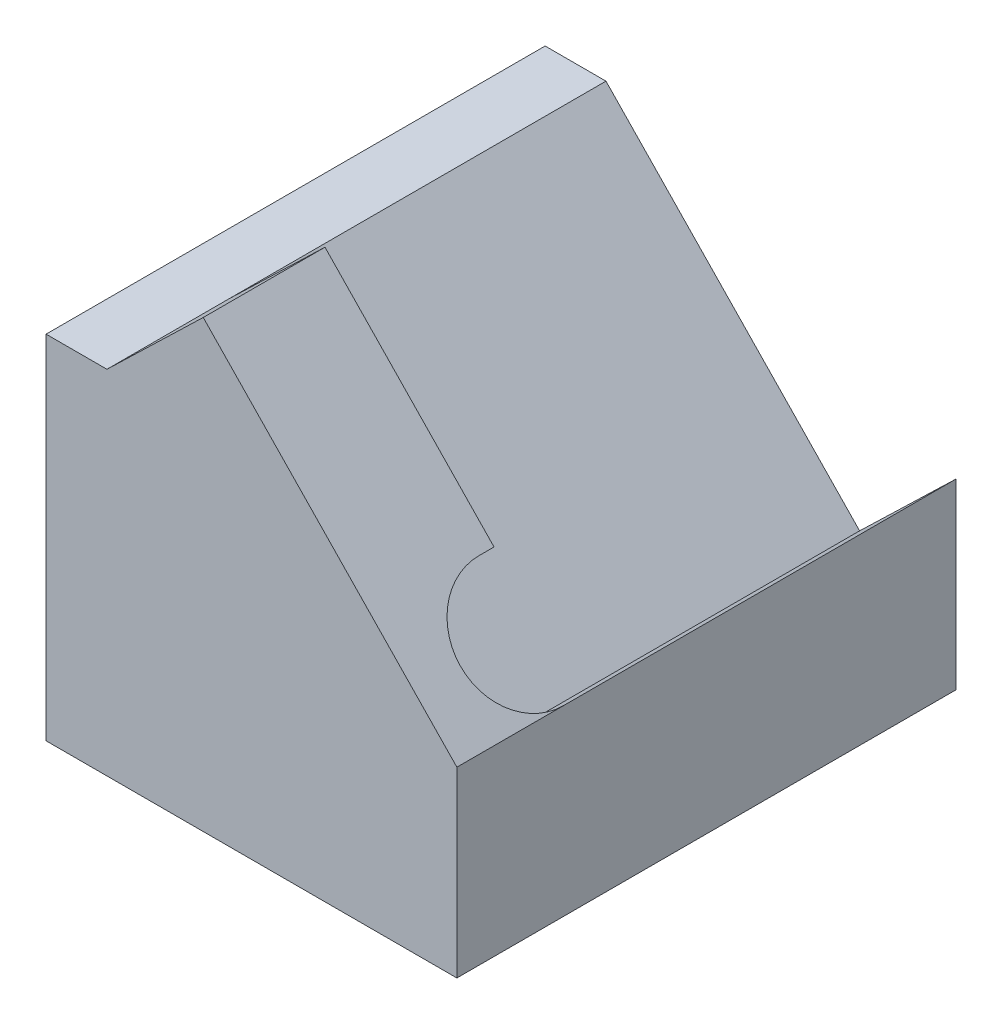
from build123d import *

# Parameters (mm, degrees)
BOSS_EXTRUDE1_DEPTH       = 8.2
CUT_EXTRUDE1_DEPTH        = 2.2
SKETCH7_W                 = 6.75
SKETCH7_H                 = 8.2
BOSS_EXTRUDE2_DEPTH       = 1
F_1_5MM_DOWEL_HOLE1_D     = 1.5
F_1_5MM_DOWEL_HOLE1_DEPTH = 1.5
F_1_5MM_DOWEL_HOLE1_TIP   = 0.450645464
M2X0_4_TAPPED_HOLE1_D     = 1.6
M2X0_4_TAPPED_HOLE1_DEPTH = 2.5
M2X0_4_TAPPED_HOLE1_TIP   = 0.480688495


with BuildPart() as part:
    # Sketch1 → Boss-Extrude1 (new body)
    with BuildSketch(Plane.XY):
        Polygon((0, 0), (0, 4.787274917), (1, 4.787274917), (2.582547561, 6.315523332), (6.75, 2), (6.75, 0), align=None)
    extrude(amount=BOSS_EXTRUDE1_DEPTH)

    # Sketch2 → Cut-Extrude1 (cut)
    with BuildSketch(Plane(origin=(4.492176628, 4.338044544, 0), x_dir=(0, 0, -1), z_dir=(0.7193398, 0.69465837, 0))):
        with BuildLine():
            Line((0, -3.2502644), (-6.45, -3.2502644))
            ThreePointArc((-6.45, -3.2502644), (-7.45, -2.2502644), (-6.45, -1.2502644))
            Line((-6.45, -1.2502644), (-6.2, -1.2502644))
            Line((-6.2, -1.2502644), (-6.2, 3.2497356))
            Line((-6.2, 3.2497356), (0, 3.2497356))
            Line((0, 3.2497356), (0, -3.2502644))
        make_face()
    extrude(amount=-CUT_EXTRUDE1_DEPTH, mode=Mode.SUBTRACT)

    # Sketch7 → Boss-Extrude2 (add)
    with BuildSketch(Plane.XZ):
        with Locations((3.375, 4.1)):
            Rectangle(SKETCH7_W, SKETCH7_H)
    extrude(amount=BOSS_EXTRUDE2_DEPTH)

    # Ø1.5mm Dowel Hole1
    with Locations(Plane(origin=(0, -1, 0), x_dir=(-1, 0, 0), z_dir=(0, -1, 0))):
        with Locations((-3, -7.1), (-3, -1.1)):
            Hole(F_1_5MM_DOWEL_HOLE1_D / 2, depth=F_1_5MM_DOWEL_HOLE1_DEPTH)
            with Locations((0, 0, -(F_1_5MM_DOWEL_HOLE1_DEPTH + F_1_5MM_DOWEL_HOLE1_TIP / 2))):  # 118° drill point
                Cone(0, F_1_5MM_DOWEL_HOLE1_D / 2, F_1_5MM_DOWEL_HOLE1_TIP, mode=Mode.SUBTRACT)

    # M2x0.4 Tapped Hole1
    with Locations(Plane(origin=(0, -1, 0), x_dir=(-1, 0, 0), z_dir=(0, -1, 0))):
        with Locations((-3, -4.1)):
            Hole(M2X0_4_TAPPED_HOLE1_D / 2, depth=M2X0_4_TAPPED_HOLE1_DEPTH)
            with Locations((0, 0, -(M2X0_4_TAPPED_HOLE1_DEPTH + M2X0_4_TAPPED_HOLE1_TIP / 2))):  # 118° drill point
                Cone(0, M2X0_4_TAPPED_HOLE1_D / 2, M2X0_4_TAPPED_HOLE1_TIP, mode=Mode.SUBTRACT)


solid = part.part
